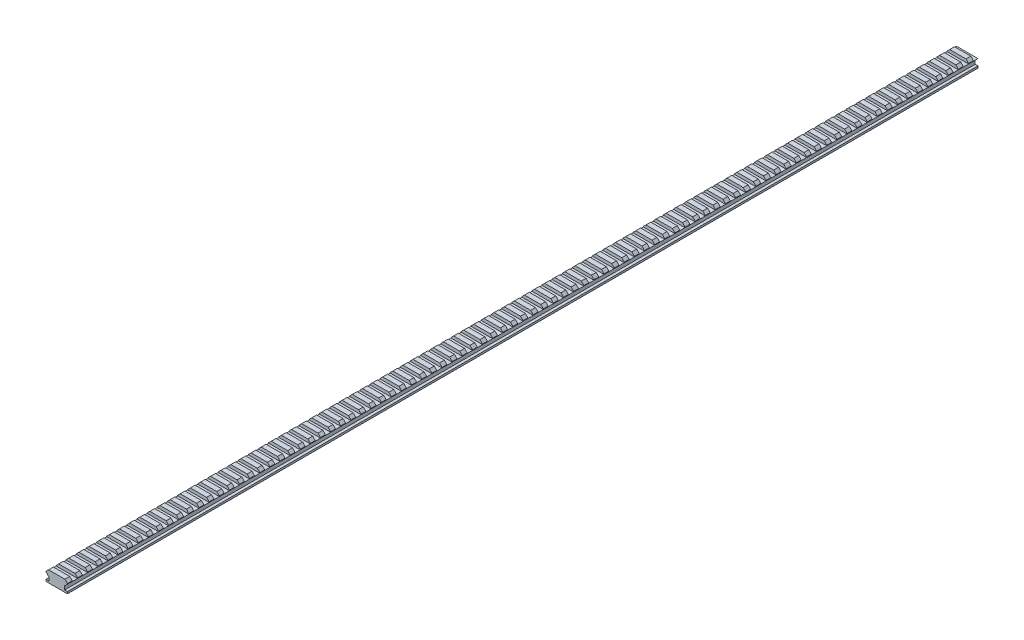
from build123d import *

# Parameters (mm, degrees)
BOSS_EXTRUDE1_DEPTH = 900
SKETCH2_W           = 5.2324
SKETCH2_H           = 3.0607
CUT_EXTRUDE1_DEPTH  = 22.209
LPATTERN2_COUNT     = 90
LPATTERN2_PITCH     = 10.0076


with BuildPart() as part:
    # Sketch1 → Boss-Extrude1 (new body)
    with BuildSketch(Plane.XY):
        Polygon((10.6045, -3.0607), (10.6045, -2.5273), (8.0772, 0), (-8.0772, 0), (-10.6045, -2.5273), (-10.6045, -3.0607), (-8.0772, -5.588), (-7.8359, -5.588), (-7.8359, -9.3218), (-10.6045, -9.3218), (-10.6045, -11.24361169), (10.6045, -11.24361169), (10.6045, -9.3218), (7.8359, -9.3218), (7.8359, -5.588), (8.0772, -5.588), align=None)
    extrude(amount=-BOSS_EXTRUDE1_DEPTH)

    # Sketch2 → Cut-Extrude1 (cut, through all)
    with BuildSketch(Plane(origin=(10.6045, 0, 0), x_dir=(0, 0, -1), z_dir=(1, 0, 0))):
        with Locations((7.3914, -1.53035)):
            Rectangle(SKETCH2_W, SKETCH2_H)
    cut_extrude1 = extrude(amount=-CUT_EXTRUDE1_DEPTH, mode=Mode.SUBTRACT)

    # LPattern2: Cut-Extrude1 ×90
    with Locations(*[(0, 0, -i * LPATTERN2_PITCH) for i in range(1, LPATTERN2_COUNT)]):
        add(cut_extrude1, mode=Mode.SUBTRACT)


solid = part.part
